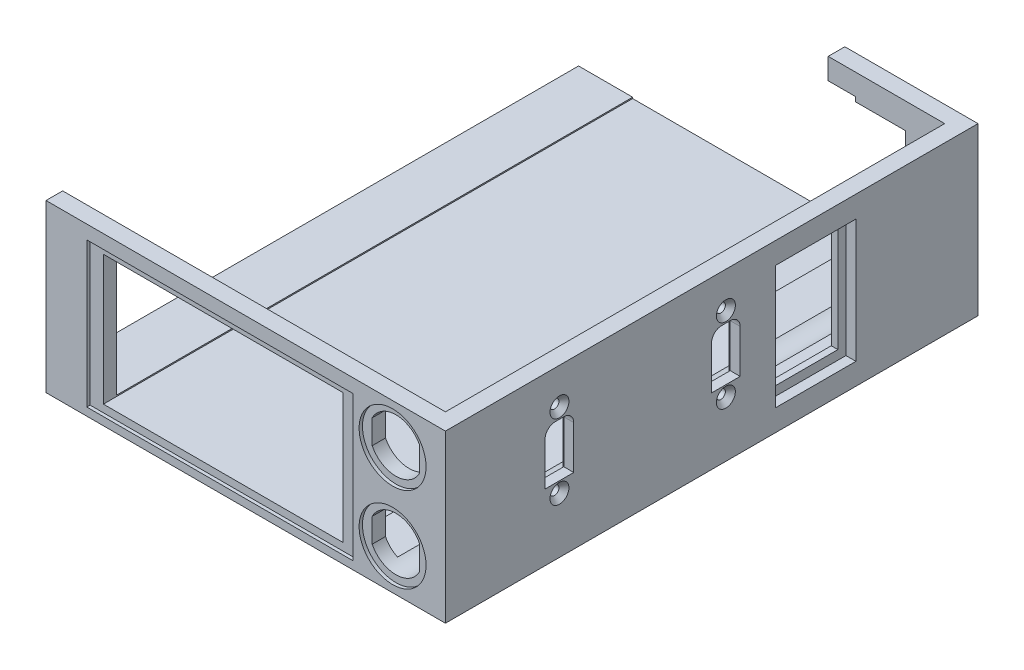
from build123d import *

# Parameters (mm, degrees)
SKETCH1_W                  = 120
SKETCH1_H                  = 50
BOSS_EXTRUDE1_DEPTH        = 160
SHELL1_T                   = -5
CUT_EXTRUDE2_REACH         = 174.699
SKETCH4_W                  = 72
SKETCH4_H                  = 39
SKETCH5_W                  = 80
SKETCH5_H                  = 43.5
CUT_EXTRUDE3_DEPTH         = 1
CUT_EXTRUDE4_REACH         = 174.699
SKETCH7_R                  = 10.054878977
CUT_EXTRUDE5_DEPTH         = 1
CUT_EXTRUDE6_REACH         = 203.556
SKETCH9_R                  = 1.35
CHAMFER1_SIZE              = 1.5
SKETCH10_W                 = 12
SKETCH10_H                 = 28
CUT_EXTRUDE7_DEPTH         = 2
LPATTERN1_COUNT            = 2
LPATTERN1_PITCH            = 50
CHAMFER1_OF_LPATTERN1_SIZE = 1.5
SKETCH11_W                 = 19.287715199
SKETCH11_H                 = 31.517777442
CUT_EXTRUDE8_DEPTH         = 202.556443707
SKETCH12_W                 = 24.096142941
SKETCH12_H                 = 37.033540034
CUT_EXTRUDE9_DEPTH         = 3
CUT_EXTRUDE10_REACH        = 174.699
SKETCH13_W                 = 24.602100194
SKETCH13_H                 = 34.536068778
SKETCH2_W                  = 80
SKETCH2_H                  = 57.520884572
CUT_EXTRUDE1_DEPTH         = 177.705970471


with BuildPart() as part:
    # Sketch1 → Boss-Extrude1 (new body)
    with BuildSketch(Plane.XY):
        Rectangle(SKETCH1_W, SKETCH1_H)
    extrude(amount=-BOSS_EXTRUDE1_DEPTH)

    # Shell1
    shell1_openings = [part.faces().sort_by_distance(p)[0] for p in [
        (-60, 0, -80),
        (0, 25, -80),
    ]]
    offset(amount=SHELL1_T, openings=shell1_openings, kind=Kind.INTERSECTION)

    # Sketch4 → Cut-Extrude2 (cut, up to next)
    with BuildSketch(Plane.XY, mode=Mode.PRIVATE) as cut_extrude2_sk1:
        with Locations((-7.752822836, -0.864806595)):
            Rectangle(SKETCH4_W, SKETCH4_H)
    cut_extrude2_tool1 = extrude(cut_extrude2_sk1.sketch, amount=-CUT_EXTRUDE2_REACH, mode=Mode.PRIVATE) & part.part
    add(cut_extrude2_tool1.solids().sort_by_distance((-7.752823, -0.864807, 0))[0], mode=Mode.SUBTRACT)

    # Sketch5 → Cut-Extrude3 (cut)
    with BuildSketch(Plane.XY):
        with Locations((-7.752822836, -0.864806595)):
            Rectangle(SKETCH5_W, SKETCH5_H)
    extrude(amount=-CUT_EXTRUDE3_DEPTH, mode=Mode.SUBTRACT)

    # Sketch6 → Cut-Extrude4 (cut, up to next)
    with BuildSketch(Plane.XY, mode=Mode.PRIVATE) as cut_extrude4_sk1:
        with BuildLine():
            Line((51.25624878, 9.193705725), (51.25624878, 16.439437846))
            ThreePointArc((51.25624878, 16.439437846), (44.123588582, 20.816571785), (36.990928383, 16.439437846))
            Line((36.990928383, 16.439437846), (36.990928383, 9.193705725))
            ThreePointArc((36.990928383, 9.193705725), (44.123588582, 4.816571785), (51.25624878, 9.193705725))
        make_face()
    cut_extrude4_tool1 = extrude(cut_extrude4_sk1.sketch, amount=-CUT_EXTRUDE4_REACH, mode=Mode.PRIVATE) & part.part
    cut_extrude4 = cut_extrude4_tool1.solids().sort_by_distance((44.123589, 12.816572, 0))[0]
    add(cut_extrude4, mode=Mode.SUBTRACT)

    # Sketch7 → Cut-Extrude5 (cut)
    with BuildSketch(Plane.XY):
        with Locations((44.123588582, 12.816571785)):
            Circle(SKETCH7_R)
    cut_extrude5 = extrude(amount=-CUT_EXTRUDE5_DEPTH, mode=Mode.SUBTRACT)

    # Mirror1: Cut-Extrude4, Cut-Extrude5 mirrored; each copy of Cut-Extrude4 runs up to whatever stops it at its own place
    mirror1_before = part.part  # the part as the pattern finds it: every copy runs up to it
    mirror1_cut_extrude4_long = extrude(cut_extrude4_sk1.sketch, amount=-CUT_EXTRUDE4_REACH, mode=Mode.PRIVATE)
    mirror1_cut_extrude4_tool = mirror1_cut_extrude4_long.mirror(Plane.ZX) & mirror1_before
    add(mirror1_cut_extrude4_tool.solids().sort_by_distance((44.123589, -12.816572, 0))[0], mode=Mode.SUBTRACT)
    add(cut_extrude5.mirror(Plane.ZX), mode=Mode.SUBTRACT)

    # Sketch9 → Cut-Extrude6 (cut, up to next)
    with BuildSketch(Plane(origin=(60, 0, 0), x_dir=(0, 0, -1), z_dir=(1, 0, 0)), mode=Mode.PRIVATE) as cut_extrude6_sk1:
        with Locations((34.250404533, 14.202757041)):
            Circle(SKETCH9_R)
    cut_extrude6_tool1 = extrude(cut_extrude6_sk1.sketch, amount=-CUT_EXTRUDE6_REACH, mode=Mode.PRIVATE) & part.part
    # Sketch9 → Cut-Extrude6 (cut, up to next)
    with BuildSketch(Plane(origin=(60, 0, 0), x_dir=(0, 0, -1), z_dir=(1, 0, 0)), mode=Mode.PRIVATE) as cut_extrude6_sk2:
        with Locations((34.250404533, -8.297242959)):
            Circle(SKETCH9_R)
    cut_extrude6_tool2 = extrude(cut_extrude6_sk2.sketch, amount=-CUT_EXTRUDE6_REACH, mode=Mode.PRIVATE) & part.part
    # Sketch9 → Cut-Extrude6 (cut, up to next)
    with BuildSketch(Plane(origin=(60, 0, 0), x_dir=(0, 0, -1), z_dir=(1, 0, 0)), mode=Mode.PRIVATE) as cut_extrude6_sk3:
        with BuildLine():
            Line((29.950404533, -5.047242959), (38.550404533, -5.047242959))
            Line((38.550404533, -5.047242959), (38.550404533, 7.952757041))
            ThreePointArc((38.550404533, 7.952757041), (37.671724876, 10.074077384), (35.550404533, 10.952757041))
            Line((35.550404533, 10.952757041), (32.950404533, 10.952757041))
            ThreePointArc((32.950404533, 10.952757041), (30.829084189, 10.074077384), (29.950404533, 7.952757041))
            Line((29.950404533, 7.952757041), (29.950404533, -5.047242959))
        make_face()
    cut_extrude6_tool3 = extrude(cut_extrude6_sk3.sketch, amount=-CUT_EXTRUDE6_REACH, mode=Mode.PRIVATE) & part.part
    cut_extrude6_1 = cut_extrude6_tool1.solids().sort_by_distance((60, 14.202757, -34.250405))[0]
    add(cut_extrude6_1, mode=Mode.SUBTRACT)
    cut_extrude6_2 = cut_extrude6_tool2.solids().sort_by_distance((60, -8.297243, -34.250405))[0]
    add(cut_extrude6_2, mode=Mode.SUBTRACT)
    cut_extrude6_3 = cut_extrude6_tool3.solids().sort_by_distance((60, 2.741042, -34.250405))[0]
    add(cut_extrude6_3, mode=Mode.SUBTRACT)
    cut_extrude6 = cut_extrude6_1 + cut_extrude6_2 + cut_extrude6_3  # Cut-Extrude6 as one shape, for the pattern or mirror that repeats it

    # Chamfer1
    chamfer1_edges = [part.edges().sort_by_distance(p)[0] for p in [
        (60, -8.297242959, -32.900404533),
        (60, 14.202757041, -32.900404533),
    ]]
    chamfer(chamfer1_edges, length=CHAMFER1_SIZE)

    # Sketch10 → Cut-Extrude7 (cut)
    with BuildSketch(Plane.ZY.offset(-55)):
        with Locations((-34.250404533, 2.952757041)):
            Rectangle(SKETCH10_W, SKETCH10_H)
    cut_extrude7 = extrude(amount=-CUT_EXTRUDE7_DEPTH, mode=Mode.SUBTRACT)

    # LPattern1: Cut-Extrude6, Cut-Extrude7 ×2
    with Locations(*[(0, 0, -i * LPATTERN1_PITCH) for i in range(1, LPATTERN1_COUNT)]):
        add(cut_extrude6, mode=Mode.SUBTRACT)
        add(cut_extrude7, mode=Mode.SUBTRACT)

    # Chamfer1 of LPattern1
    chamfer1_of_lpattern1_edges = [part.edges().sort_by_distance(p)[0] for p in [
        (60, -8.297242959, -82.900404533),
        (60, 14.202757041, -82.900404533),
    ]]
    chamfer(chamfer1_of_lpattern1_edges, length=CHAMFER1_OF_LPATTERN1_SIZE)

    # Sketch11 → Cut-Extrude8 (cut, through all)
    with BuildSketch(Plane(origin=(60, 0, 0), x_dir=(0, 0, -1), z_dir=(1, 0, 0))):
        with Locations((111.274658912, 0)):
            Rectangle(SKETCH11_W, SKETCH11_H)
    extrude(amount=-CUT_EXTRUDE8_DEPTH, mode=Mode.SUBTRACT)

    # Sketch12 → Cut-Extrude9 (cut)
    with BuildSketch(Plane(origin=(60, 0, 0), x_dir=(0, 0, -1), z_dir=(1, 0, 0))):
        with Locations((111.274658912, 0)):
            Rectangle(SKETCH12_W, SKETCH12_H)
    extrude(amount=-CUT_EXTRUDE9_DEPTH, mode=Mode.SUBTRACT)

    # Sketch13 → Cut-Extrude10 (cut, up to next)
    with BuildSketch(Plane(origin=(0, 0, -160), x_dir=(-1, 0, 0), z_dir=(0, 0, -1)), mode=Mode.PRIVATE) as cut_extrude10_sk1:
        with Locations((-30.86599902, 0)):
            Rectangle(SKETCH13_W, SKETCH13_H)
    cut_extrude10_tool1 = extrude(cut_extrude10_sk1.sketch, amount=-CUT_EXTRUDE10_REACH, mode=Mode.PRIVATE) & part.part
    add(cut_extrude10_tool1.solids().sort_by_distance((30.865999, 0, -160))[0], mode=Mode.SUBTRACT)

    # Sketch2 → Cut-Extrude1 (cut, through all)
    with BuildSketch(Plane(origin=(0, -20, 0), x_dir=(1, 0, 0), z_dir=(0, 1, 0))):
        with Locations((-20, 183.760442286)):
            Rectangle(SKETCH2_W, SKETCH2_H)
    extrude(amount=CUT_EXTRUDE1_DEPTH, mode=Mode.SUBTRACT)


solid = part.part
